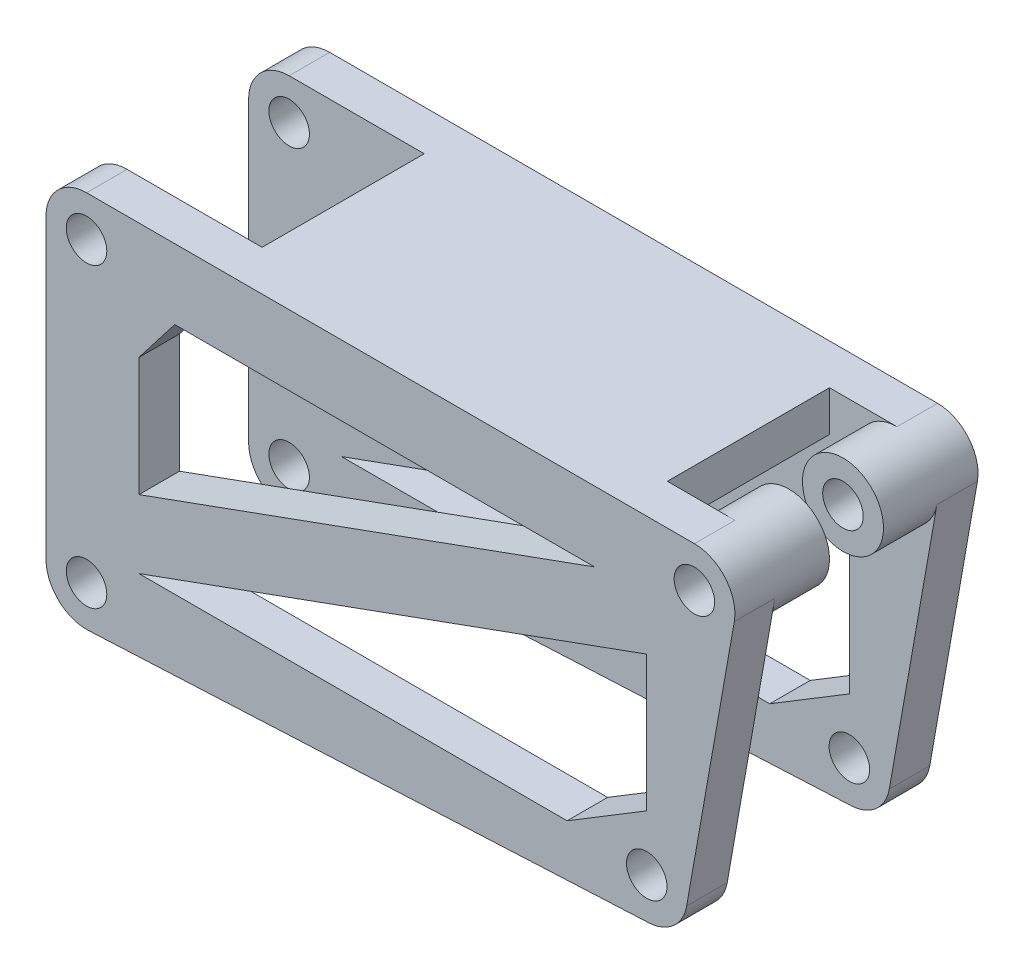
from build123d import *

# Parameters (mm, degrees)
SKETCH1_R           = 1.5
BOSS_EXTRUDE1_DEPTH = 3
LPATTERN1_COUNT     = 2
LPATTERN1_PITCH     = 15
SKETCH2_R           = 3
SKETCH2_R_2         = 1.5
BOSS_EXTRUDE2_DEPTH = 4
LPATTERN2_COUNT     = 2
LPATTERN2_PITCH     = 8
SKETCH3_W           = 30
SKETCH3_H           = 3
BOSS_EXTRUDE3_DEPTH = 15


with BuildPart() as part:
    # Sketch1 → Boss-Extrude1 (new body)
    with BuildSketch(Plane.XY):
        with BuildLine():
            Line((0, 3), (45, 3))
            ThreePointArc((45, 3), (47.298133329, 1.928362829), (47.954423259, -0.520944533))
            Line((47.954423259, -0.520944533), (44.427883645, -20.520944533))
            ThreePointArc((44.427883645, -20.520944533), (43.456627447, -22.25101053), (41.617963293, -22.996517797))
            Line((41.617963293, -22.996517797), (0.144502907, -24.996517797))
            ThreePointArc((0.144502907, -24.996517797), (-2.069600357, -24.171809006), (-3, -22))
            Line((-3, -22), (-3, 0))
            ThreePointArc((-3, 0), (-2.121320344, 2.121320344), (0, 3))
        make_face()
        with Locations((45, 0)):
            Circle(SKETCH1_R, mode=Mode.SUBTRACT)
        with Locations((41.473460386, -20)):
            Circle(SKETCH1_R, mode=Mode.SUBTRACT)
        with Locations((0, -22)):
            Circle(SKETCH1_R, mode=Mode.SUBTRACT)
        Circle(SKETCH1_R, mode=Mode.SUBTRACT)
        Polygon((3.881124623, -14.414030159), (3.881124623, -5.613630965), (6.529032345, -2.186926854), (37.60300826, -2.186926854), align=None, mode=Mode.SUBTRACT)
        Polygon((3.881124623, -19.476206686), (41.473460386, -5.845729285), (41.473460386, -15.893743297), (35.578137649, -19.476206686), align=None, mode=Mode.SUBTRACT)
    extrude(amount=BOSS_EXTRUDE1_DEPTH)


with BuildPart() as lpattern1_1:
    # LPattern1: pattern copy
    add(part.part.moved(Location(Vector(0, 0, 1) * (1 * LPATTERN1_PITCH))))


with BuildPart() as part_1:
    add(part.part)

    # Sketch2 → Boss-Extrude2 (add)
    with BuildSketch(Plane.XY.offset(3)):
        with Locations((45, 0)):
            Circle(SKETCH2_R)
        with Locations((45, 0)):
            Circle(SKETCH2_R_2, mode=Mode.SUBTRACT)
    boss_extrude2 = extrude(amount=BOSS_EXTRUDE2_DEPTH)



with BuildPart() as lpattern1_1_1:
    add(lpattern1_1.part)

    # LPattern2: Boss-Extrude2 ×2
    with Locations(*[(0, 0, i * LPATTERN2_PITCH) for i in range(1, LPATTERN2_COUNT)]):
        add(boss_extrude2)


with BuildPart() as part_2:
    add(part_1.part)

    add(lpattern1_1_1.part)  # Boss-Extrude3 merges LPattern1_1
    # Sketch3 → Boss-Extrude3 (add)
    with BuildSketch(Plane.XY.offset(3)):
        with Locations((25, 1.5)):
            Rectangle(SKETCH3_W, SKETCH3_H)
    extrude(amount=BOSS_EXTRUDE3_DEPTH)


solid = part_2.part
